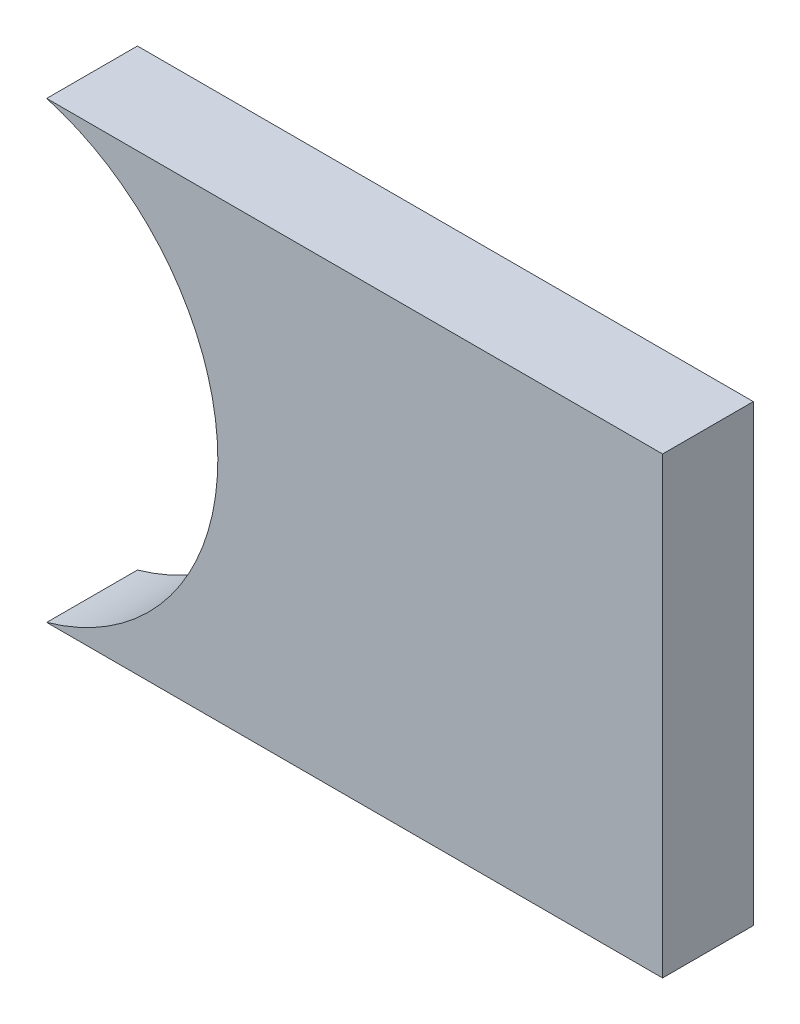
from build123d import *

# Parameters (mm, degrees)
BOSS_EXTRUDE1_DEPTH = 2


with BuildPart() as part:
    # Sketch1 → Boss-Extrude1 (new body)
    with BuildSketch(Plane.XY):
        with BuildLine():
            Line((-10.396049823, -5.488799617), (-23.967764137, -5.488799617))
            ThreePointArc((-23.967764137, -5.488799617), (-21.24471958, -7.357273277), (-20.196049823, -10.488799617))
            ThreePointArc((-20.196049823, -10.488799617), (-21.24471958, -13.620325957), (-23.967764137, -15.488799617))
            Line((-23.967764137, -15.488799617), (-10.396049823, -15.488799617))
            Line((-10.396049823, -15.488799617), (-10.396049823, -5.488799617))
        make_face()
    extrude(amount=BOSS_EXTRUDE1_DEPTH)


solid = part.part
